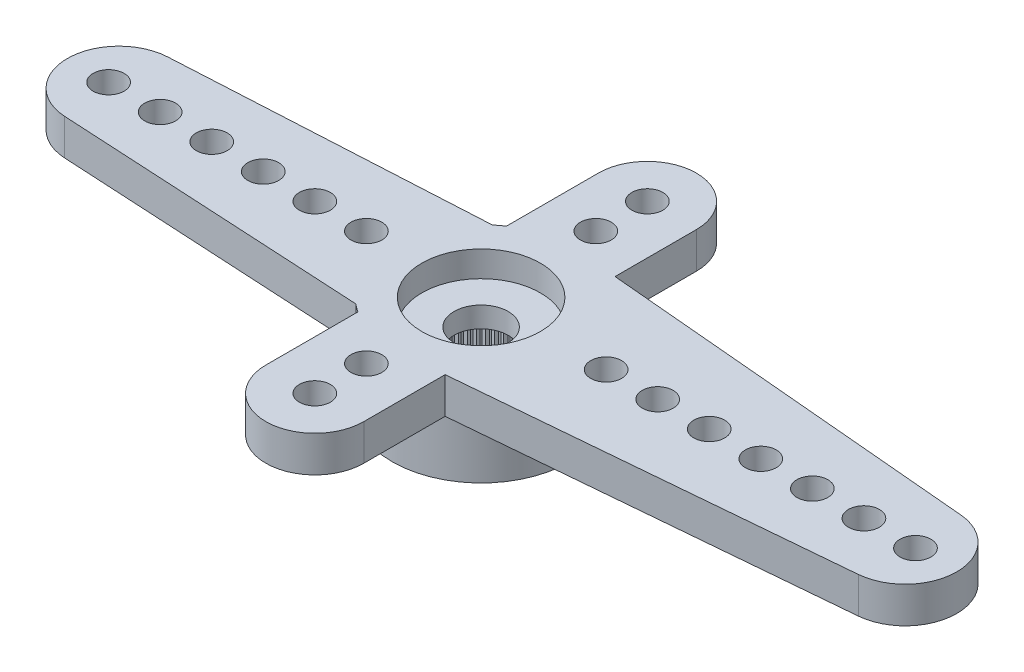
from build123d import *

# Parameters (mm, degrees)
RESSALTO_EXTRUS_O1_DEPTH = 1.4
ESBO_O2_R                = 3.45
RESSALTO_EXTRUS_O2_DEPTH = 2.4
FURO1_D                  = 1.2
PADR_O_LINEAR1_COUNT     = 6
PADR_O_LINEAR1_PITCH     = 2
RESSALTO_EXTRUS_O3_DEPTH = 1.4
FURO2_D                  = 1.2
PADR_O_LINEAR2_COUNT     = 7
PADR_O_LINEAR2_PITCH     = 2
RESSALTO_EXTRUS_O4_DEPTH = 1.4
FURO3_D                  = 1.2
PADR_O_LINEAR3_COUNT     = 2
PADR_O_LINEAR3_PITCH     = 2
PADR_OCIRCULAR1_COUNT    = 2
PADR_OCIRCULAR1_COPY_1_D = 1.2
FURO4_D                  = 4.95
FURO4_DEPTH              = 2
FURO5_D                  = 4.6
FURO5_DEPTH              = 1
FURO6_D                  = 2.1
RESSALTO_EXTRUS_O5_DEPTH = 2
PADR_OCIRCULAR2_COUNT    = 60


with BuildPart() as part:
    # Esboço1 → Ressalto-extrusão1 (new body)
    with BuildSketch(Plane(origin=(0, 0, 0), x_dir=(1, 0, 0), z_dir=(0, 1, 0))):
        with BuildLine():
            Line((-14.159121967, 1.99702088), (-2.209072203, 2.65))
            ThreePointArc((-2.209072203, 2.65), (3.45, 0), (-2.209072203, -2.65))
            Line((-2.209072203, -2.65), (-14.159121967, -1.99702088))
            ThreePointArc((-14.159121967, -1.99702088), (-16.05, 0), (-14.159121967, 1.99702088))
        make_face()
    extrude(amount=-RESSALTO_EXTRUS_O1_DEPTH)

    # Esboço2 → Ressalto-extrusão2 (add)
    with BuildSketch(Plane.XZ.offset(1.4)):
        Circle(ESBO_O2_R)
    extrude(amount=RESSALTO_EXTRUS_O2_DEPTH)

    # Furo1 (through all)
    with Locations(Plane(origin=(0, 0, 0), x_dir=(1, 0, 0), z_dir=(0, 1, 0))):
        with Locations((-14.45, 0)):
            furo1 = Hole(FURO1_D / 2)

    # Padrão linear1: Furo1 ×6
    with Locations(*[(i * PADR_O_LINEAR1_PITCH, 0, 0) for i in range(1, PADR_O_LINEAR1_COUNT)]):
        add(furo1, mode=Mode.SUBTRACT)

    # Esboço12 → Ressalto-extrusão3 (add)
    with BuildSketch(Plane(origin=(0, 0, 0), x_dir=(1, 0, 0), z_dir=(0, 1, 0))):
        with BuildLine():
            Line((0.304103343, 3.436571134), (16.626291793, 1.99221515))
            ThreePointArc((16.626291793, 1.99221515), (18.45, 0), (16.626291793, -1.99221515))
            Line((16.626291793, -1.99221515), (0.304103343, -3.436571134))
            ThreePointArc((0.304103343, -3.436571134), (3.45, 0), (0.304103343, 3.436571134))
        make_face()
    extrude(amount=-RESSALTO_EXTRUS_O3_DEPTH)

    # Furo2 (through all)
    with Locations(Plane(origin=(0, 0, 0), x_dir=(1, 0, 0), z_dir=(0, 1, 0))):
        with Locations((16.85, 0)):
            furo2 = Hole(FURO2_D / 2)

    # Padrão linear2: Furo2 ×7
    with Locations(*[(-i * PADR_O_LINEAR2_PITCH, 0, 0) for i in range(1, PADR_O_LINEAR2_COUNT)]):
        add(furo2, mode=Mode.SUBTRACT)

    # Esboço16 → Ressalto-extrusão4 (add)
    with BuildSketch(Plane(origin=(0, 0, 0), x_dir=(1, 0, 0), z_dir=(0, 1, 0))):
        with BuildLine():
            Line((-1.9, -6.45), (-1.9, 6.45))
            ThreePointArc((-1.9, 6.45), (0, 8.35), (1.9, 6.45))
            Line((1.9, 6.45), (1.9, -6.45))
            ThreePointArc((1.9, -6.45), (0, -8.35), (-1.9, -6.45))
        make_face()
    extrude(amount=-RESSALTO_EXTRUS_O4_DEPTH)

    # Furo3 (through all)
    with Locations(Plane(origin=(0, 0, 0), x_dir=(1, 0, 0), z_dir=(0, 1, 0))):
        with Locations((0, -6.45)):
            furo3 = Hole(FURO3_D / 2)

    # Padrão linear3: Furo3 ×2
    with Locations(*[(0, 0, -i * PADR_O_LINEAR3_PITCH) for i in range(1, PADR_O_LINEAR3_COUNT)]):
        add(furo3, mode=Mode.SUBTRACT)

    # PadrãoCircular1: Furo3 ×2 about axis
    padr_ocircular1_axis = Axis((0, 0, 0), (0, 1, 0))
    for i in range(1, PADR_OCIRCULAR1_COUNT):
        add(furo3.rotate(padr_ocircular1_axis, i * 360 / PADR_OCIRCULAR1_COUNT), mode=Mode.SUBTRACT)

    # PadrãoCircular1 copy 1 (through all)
    with Locations(Plane(origin=(0, 0, 2), x_dir=(-1, 0, 0), z_dir=(0, 1, 0))):
        with Locations((0, -6.45)):
            Hole(PADR_OCIRCULAR1_COPY_1_D / 2)

    # Furo4
    with Locations(Plane(origin=(0, -3.8, 0), x_dir=(-1, 0, 0), z_dir=(0, -1, 0))):
        with Locations((0, 0)):
            Hole(FURO4_D / 2, depth=FURO4_DEPTH)

    # Furo5
    with Locations(Plane(origin=(0, 0, 0), x_dir=(1, 0, 0), z_dir=(0, 1, 0))):
        with Locations((0, 0)):
            Hole(FURO5_D / 2, depth=FURO5_DEPTH)

    # Furo6 (through all)
    with Locations(Plane(origin=(0, 0, 0), x_dir=(1, 0, 0), z_dir=(0, 1, 0))):
        with Locations((0, 0)):
            Hole(FURO6_D / 2)

    # Esboço11 → Ressalto-extrusão5 (add)
    with BuildSketch(Plane.XZ.offset(3.8)):
        with BuildLine():
            Line((-0.098056786, 2.473056786), (0, 2.375))
            Line((0, 2.375), (0.098056786, 2.473056786))
            ThreePointArc((0.098056786, 2.473056786), (0, 2.475), (-0.098056786, 2.473056786))
        make_face()
    ressalto_extrus_o5 = extrude(amount=-RESSALTO_EXTRUS_O5_DEPTH)

    # PadrãoCircular2: Ressalto-extrusão5 ×60 about axis
    padr_ocircular2_axis = Axis((0, 0, 0), (0, 1, 0))
    for i in range(1, PADR_OCIRCULAR2_COUNT):
        add(ressalto_extrus_o5.rotate(padr_ocircular2_axis, i * 360 / PADR_OCIRCULAR2_COUNT))


solid = part.part
